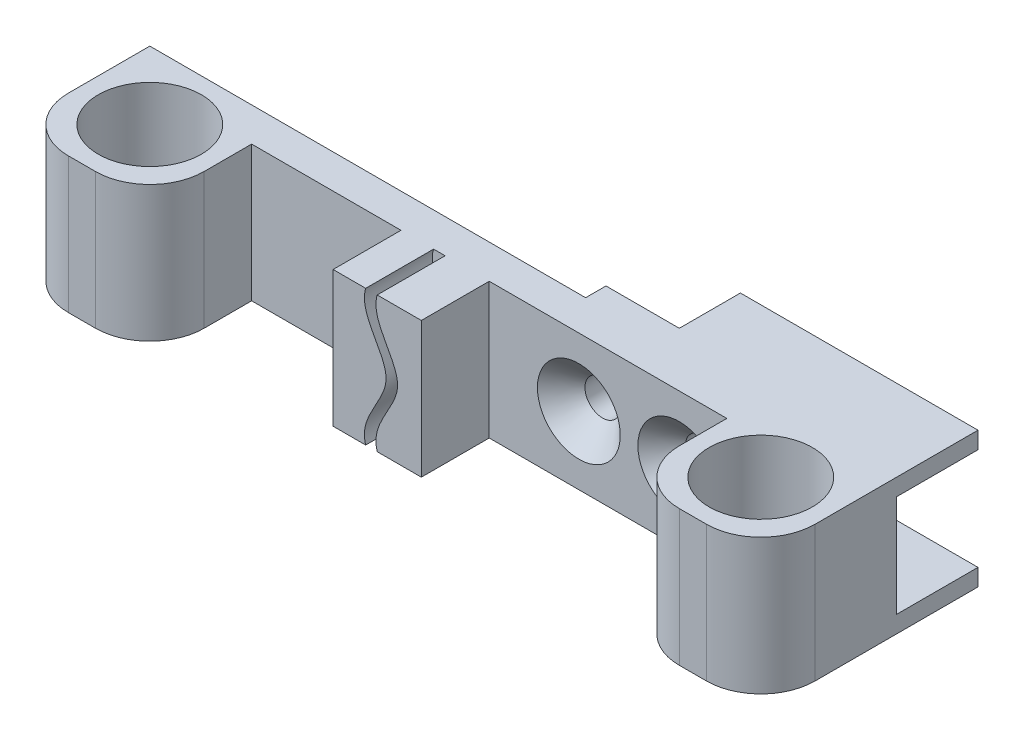
from build123d import *

# Parameters (mm, degrees)
ESQUISSE1_R                  = 7.6
BOSS_EXTRU_1_DEPTH           = 20
ESQUISSE8_W                  = 22.8
ESQUISSE8_H                  = 20
BOSS_EXTRU_4_DEPTH           = 3
ESQUISSE2_W                  = 35
ESQUISSE2_H                  = 2.5
BOSS_EXTRU_2_DEPTH           = 12
ESQUISSE3_R                  = 2.6
ENL_V_MAT_EXTRU_1_DEPTH      = 3
ENL_V_MAT_EXTRU_1_DEPTH_BACK = 22
CHANFREIN1_SIZE              = 3.5
ESQUISSE4_W                  = 10
ESQUISSE4_H                  = 20
BOSS_EXTRU_3_DEPTH           = 13
ENL_V_MAT_EXTRU_2_DEPTH      = 10


with BuildPart() as part:
    # Esquisse1 → Boss.-Extru.1 (new body)
    with BuildSketch(Plane(origin=(0, 0, 0), x_dir=(1, 0, 0), z_dir=(0, 1, 0))):
        with BuildLine():
            Line((47, -20), (43, -20))
            ThreePointArc((43, -20), (37.343145751, -17.656854249), (35, -12))
            Line((35, -12), (35, -5))
            Line((35, -5), (-35, -5))
            Line((-35, -5), (-35, -12))
            ThreePointArc((-35, -12), (-37.343145751, -17.656854249), (-43, -20))
            Line((-43, -20), (-47, -20))
            ThreePointArc((-47, -20), (-52.656854249, -17.656854249), (-55, -12))
            Line((-55, -12), (-55, 0))
            Line((-55, 0), (55, 0))
            Line((55, 0), (55, -12))
            ThreePointArc((55, -12), (52.656854249, -17.656854249), (47, -20))
        make_face()
        with Locations((45, -10)):
            Circle(ESQUISSE1_R, mode=Mode.SUBTRACT)
        with Locations((-45, -10)):
            Circle(ESQUISSE1_R, mode=Mode.SUBTRACT)
    extrude(amount=BOSS_EXTRU_1_DEPTH)

    # Esquisse8 → Boss.-Extru.4 (add)
    with BuildSketch(Plane(origin=(0, 0, 0), x_dir=(-1, 0, 0), z_dir=(0, 0, -1))):
        with Locations((-20.6, 10)):
            Rectangle(ESQUISSE8_W, ESQUISSE8_H)
    extrude(amount=BOSS_EXTRU_4_DEPTH)

    # Esquisse2 → Boss.-Extru.2 (add)
    with BuildSketch(Plane(origin=(0, 0, 0), x_dir=(-1, 0, 0), z_dir=(0, 0, -1))):
        with Locations((-37.5, 18.75)):
            Rectangle(ESQUISSE2_W, ESQUISSE2_H)
        with Locations((-37.5, 1.25)):
            Rectangle(ESQUISSE2_W, ESQUISSE2_H)
    extrude(amount=BOSS_EXTRU_2_DEPTH)

    # Esquisse3 → Enlèv. mat.-Extru.1 (cut, two sides)
    with BuildSketch(Plane(origin=(0, 0, 0), x_dir=(-1, 0, 0), z_dir=(0, 0, -1))) as enl_v_mat_extru_1_sk:
        with Locations((-13.2, 10)):
            Circle(ESQUISSE3_R)
        with Locations((-28, 10)):
            Circle(ESQUISSE3_R)
    extrude(amount=ENL_V_MAT_EXTRU_1_DEPTH, mode=Mode.SUBTRACT)
    extrude(enl_v_mat_extru_1_sk.sketch, amount=-ENL_V_MAT_EXTRU_1_DEPTH_BACK, mode=Mode.SUBTRACT)

    # Chanfrein1
    chanfrein1_edges = [part.edges().sort_by_distance(p)[0] for p in [
        (15.8, 10, 5),
        (30.6, 10, 5),
    ]]
    chamfer(chanfrein1_edges, length=CHANFREIN1_SIZE)

    # Esquisse4 → Boss.-Extru.3 (add)
    with BuildSketch(Plane(origin=(0, 0, 0), x_dir=(0, 0, -1), z_dir=(1, 0, 0))):
        with Locations((-10, 10)):
            Rectangle(ESQUISSE4_W, ESQUISSE4_H)
    extrude(amount=-BOSS_EXTRU_3_DEPTH)

    # Esquisse7 → Enlèv. mat.-Extru.2 (cut)
    with BuildSketch(Plane.XY.offset(15)):
        with BuildLine():
            Line((-8.2, 20), (-6.5, 20))
            add(Edge.make_bspline(
                [(-6.5, 20), (-7.602205078, 16.366247775), (0.602205078, 10), (-7.602205078, 3.633752225), (-6.5, 0)],
                knots=[0, 0, 0, 0, 0.5, 1, 1, 1, 1], degree=3))
            Line((-6.5, 0), (-8.2, 0))
            add(Edge.make_bspline(
                [(-8.2, 20), (-9.302205078, 16.366247775), (-1.097794922, 10), (-9.302205078, 3.633752225), (-8.2, 0)],
                knots=[0, 0, 0, 0, 0.5, 1, 1, 1, 1], degree=3))
        make_face()
    extrude(amount=-ENL_V_MAT_EXTRU_2_DEPTH, mode=Mode.SUBTRACT)


solid = part.part
